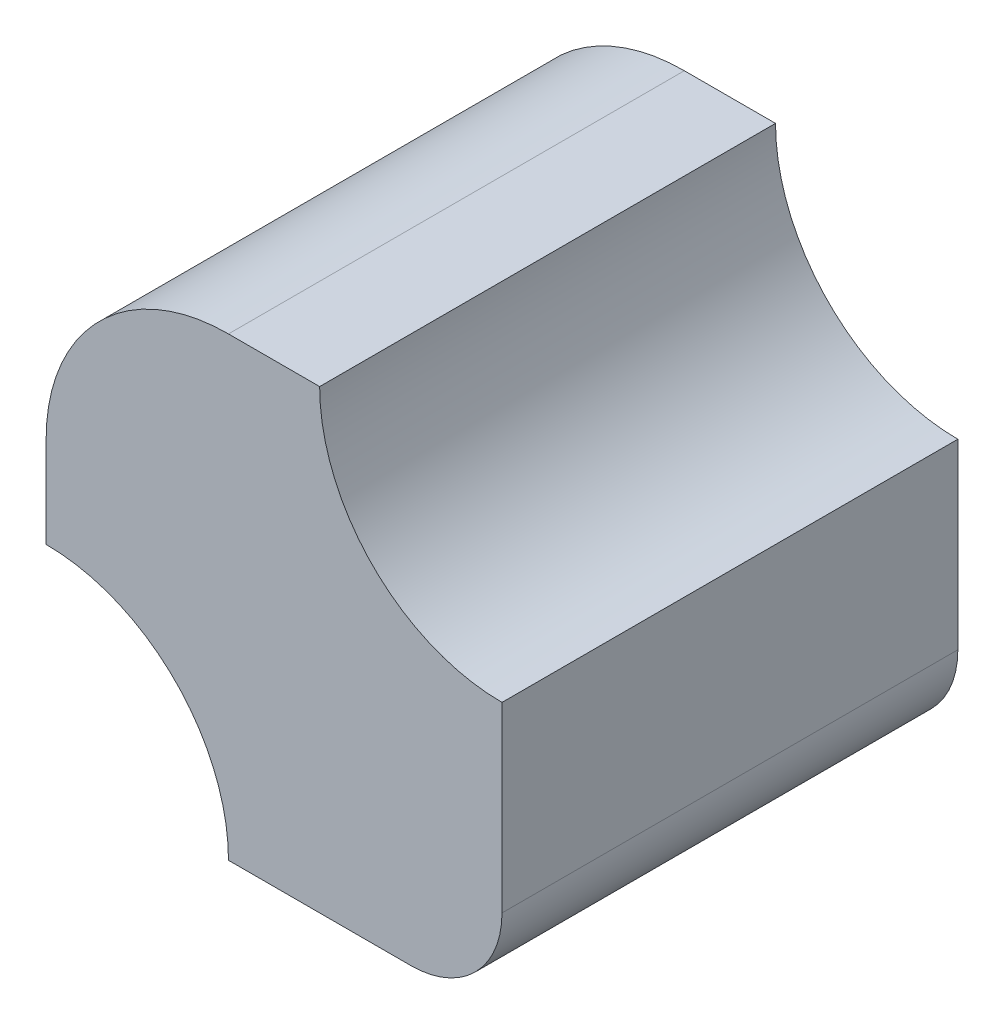
from build123d import *

# Parameters (mm, degrees)
BOSS_EXTRUDE1_DEPTH = 25


with BuildPart() as part:
    # Sketch1 → Boss-Extrude1 (new body)
    with BuildSketch(Plane.XY):
        with BuildLine():
            Line((-15, 20), (-10, 20))
            ThreePointArc((-10, 20), (-7.071067812, 12.928932188), (0, 10))
            Line((0, 10), (0, 0))
            ThreePointArc((0, 0), (-1.464466094, -3.535533906), (-5, -5))
            Line((-5, -5), (-15, -5))
            ThreePointArc((-15, -5), (-17.928932188, 2.071067812), (-25, 5))
            Line((-25, 5), (-25, 10))
            ThreePointArc((-25, 10), (-22.071067812, 17.071067812), (-15, 20))
        make_face()
    extrude(amount=BOSS_EXTRUDE1_DEPTH)


solid = part.part
